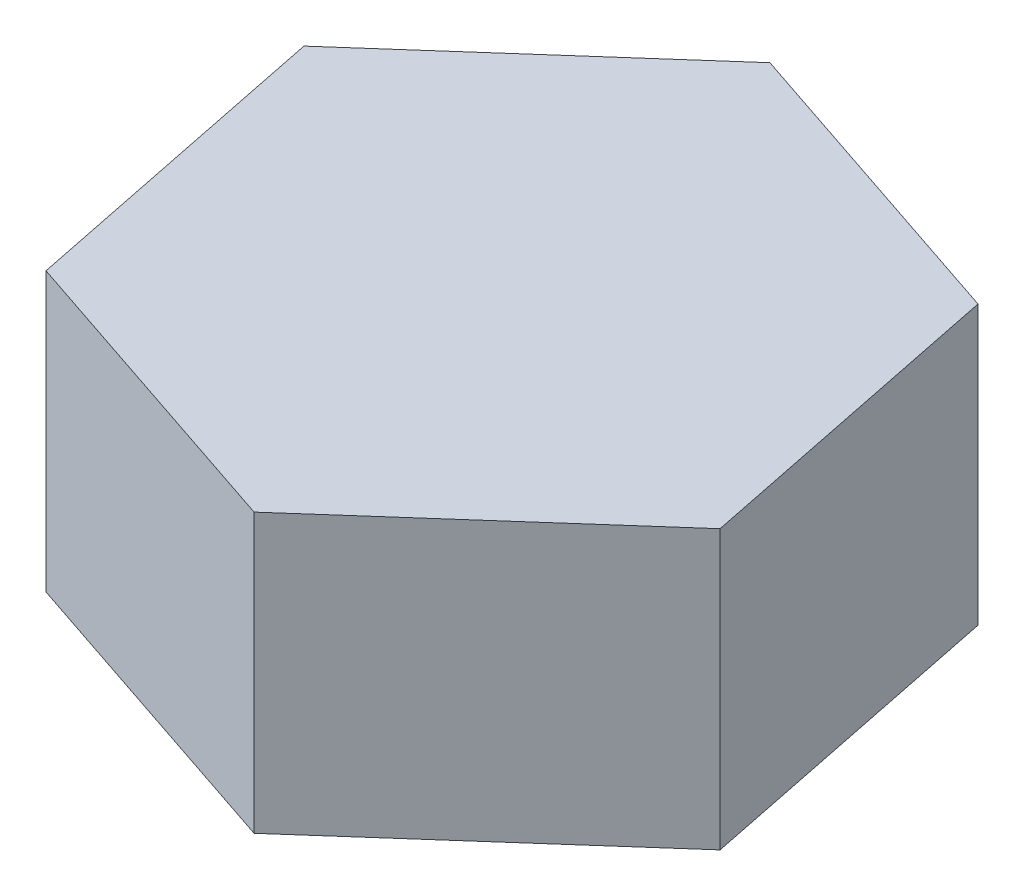
from build123d import *

# Parameters (mm, degrees)
BOSS_EXTRUDE1_DEPTH = 1.8


with BuildPart() as part:
    # Sketch1 → Boss-Extrude1 (new body)
    with BuildSketch(Plane(origin=(0, 0, 0), x_dir=(1, 0, 0), z_dir=(0, 1, 0))):
        Polygon((1.600733108, 1.414562422), (-0.424680439, 2.093556747), (-2.025413547, 0.678994325), (-1.600733108, -1.414562422), (0.424680439, -2.093556747), (2.025413547, -0.678994325), align=None)
    extrude(amount=BOSS_EXTRUDE1_DEPTH)


solid = part.part
